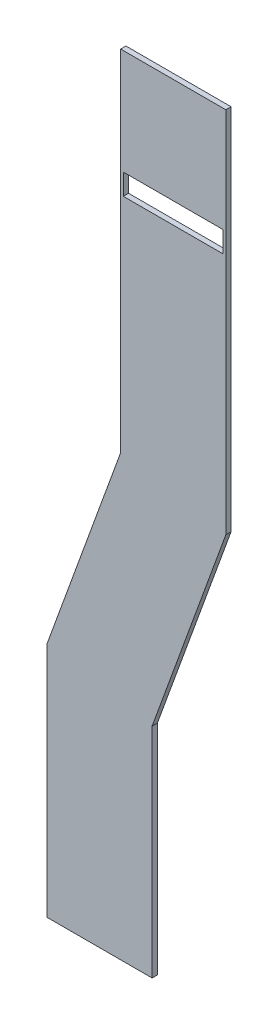
from build123d import *

# Parameters (mm, degrees)
BOSS_EXTRUDE1_DEPTH = 1
SKETCH2_W           = 19
SKETCH2_H           = 4
CUT_EXTRUDE1_DEPTH  = 1


with BuildPart() as part:
    # Sketch1 → Boss-Extrude1 (new body)
    with BuildSketch(Plane.XY):
        Polygon((0, 0), (-20, 0), (-20, -66.473460386), (-34.022513649, -105), (-34.022513649, -150), (-14.022513649, -150), (-14.022513649, -108.526539614), (0, -70), align=None)
    extrude(amount=BOSS_EXTRUDE1_DEPTH)

    # Sketch2 → Cut-Extrude1 (cut)
    with BuildSketch(Plane(origin=(0, 0, 0), x_dir=(-1, 0, 0), z_dir=(0, 0, -1))):
        with Locations((10, -22)):
            Rectangle(SKETCH2_W, SKETCH2_H)
    extrude(amount=-CUT_EXTRUDE1_DEPTH, mode=Mode.SUBTRACT)


solid = part.part
